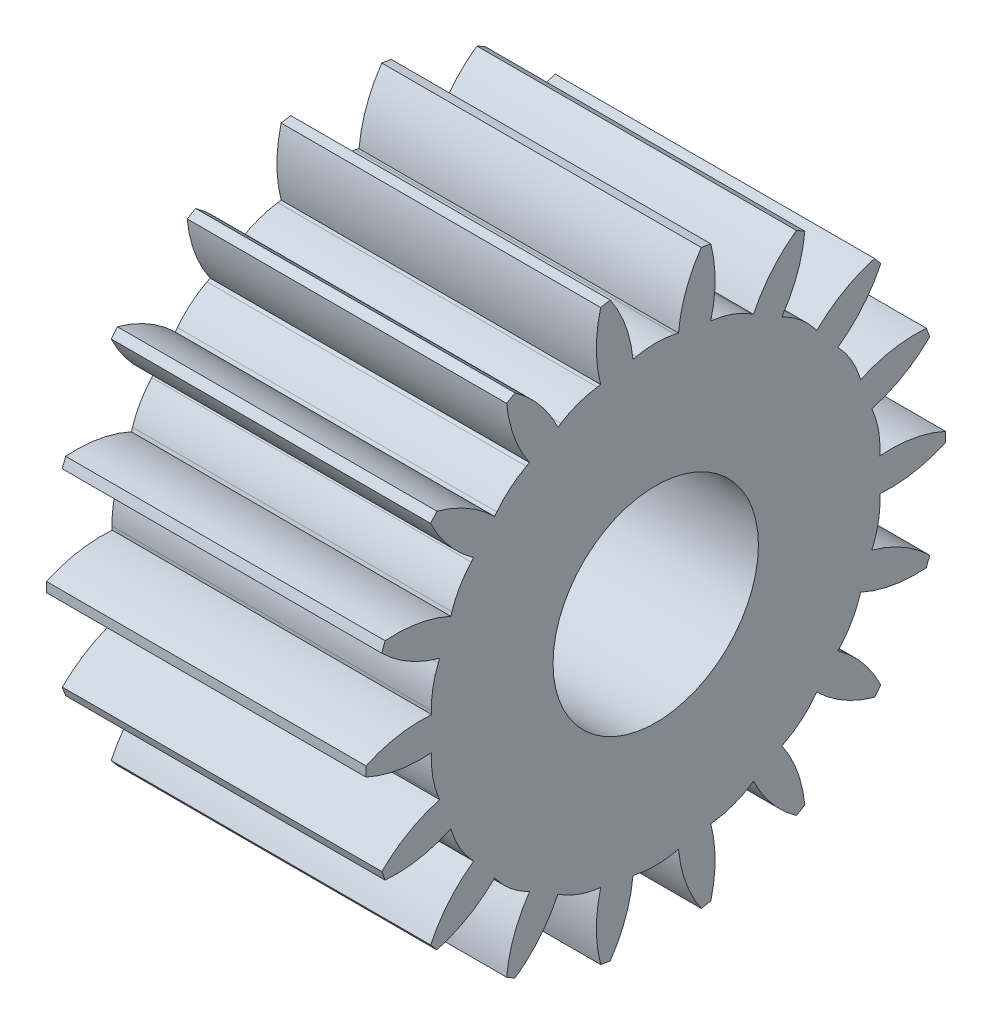
from build123d import *

# Parameters (mm, degrees)
SKETCH1_R                = 63.5
BOSS_EXTRUDE1_DEPTH      = 35
SKETCH6_R                = 22.5
CUT_EXTRUDE4_DEPTH       = 71
CUT_EXTRUDE5_DEPTH       = 71
FILLET1_R                = 20
CIRPATTERN3_COUNT        = 18
FILLET1_OF_CIRPATTERN3_R = 20


with BuildPart() as part:
    # Sketch1 → Boss-Extrude1 (new body, symmetric)
    with BuildSketch(Plane(origin=(0, 0, 0), x_dir=(0, 0, -1), z_dir=(1, 0, 0))):
        Circle(SKETCH1_R)
    extrude(amount=BOSS_EXTRUDE1_DEPTH, both=True)

    # Sketch6 → Cut-Extrude4 (cut, through all)
    with BuildSketch(Plane(origin=(35, 0, 0), x_dir=(0, 0, -1), z_dir=(1, 0, 0))):
        Circle(SKETCH6_R)
    extrude(amount=-CUT_EXTRUDE4_DEPTH, mode=Mode.SUBTRACT)

    # Sketch7 → Cut-Extrude5 (cut, through all)
    with BuildSketch(Plane(origin=(35, 0, 0), x_dir=(0, 0, -1), z_dir=(1, 0, 0))):
        with BuildLine():
            Line((0, 50.039601818), (-4.985, 48.961883134))
            ThreePointArc((-4.985, 48.961883134), (-6.597219376, 56.157134763), (-9.975, 62.711636679))
            Line((-9.975, 62.711636679), (0, 72.167588378))
            Line((0, 72.167588378), (9.975, 62.711636679))
            ThreePointArc((9.975, 62.711636679), (6.597219376, 56.157134763), (4.985, 48.961883134))
            Line((4.985, 48.961883134), (0, 50.039601818))
        make_face()
    cut_extrude5 = extrude(amount=-CUT_EXTRUDE5_DEPTH, mode=Mode.SUBTRACT)

    # Fillet1
    fillet1_edges = [part.edges().sort_by_distance(p)[0] for p in [
        (0, 50.039601818, 0),
    ]]
    fillet(fillet1_edges, radius=FILLET1_R)

    # CirPattern3: Cut-Extrude5 ×18 about axis
    cirpattern3_axis = Axis((0, 0, 0), (1, 0, 0))
    for i in range(1, CIRPATTERN3_COUNT):
        add(cut_extrude5.rotate(cirpattern3_axis, i * 360 / CIRPATTERN3_COUNT), mode=Mode.SUBTRACT)

    # Fillet1 of CirPattern3
    fillet1_of_cirpattern3_edges = [part.edges().sort_by_distance(p)[0] for p in [
        (0, 47.021844575, 17.114551786),
        (0, 38.332558908, 32.164836042),
        (0, 25.019800909, 43.335566369),
        (0, 8.689285667, 49.279387828),
        (0, -8.689285667, 49.279387828),
        (0, -25.019800909, 43.335566369),
        (0, -38.332558908, 32.164836042),
        (0, -47.021844575, 17.114551786),
        (0, -50.039601818, 0),
        (0, -47.021844575, -17.114551786),
        (0, -38.332558908, -32.164836042),
        (0, -25.019800909, -43.335566369),
        (0, -8.689285667, -49.279387828),
        (0, 8.689285667, -49.279387828),
        (0, 25.019800909, -43.335566369),
        (0, 38.332558908, -32.164836042),
        (0, 47.021844575, -17.114551786),
    ]]
    fillet(fillet1_of_cirpattern3_edges, radius=FILLET1_OF_CIRPATTERN3_R)


solid = part.part
